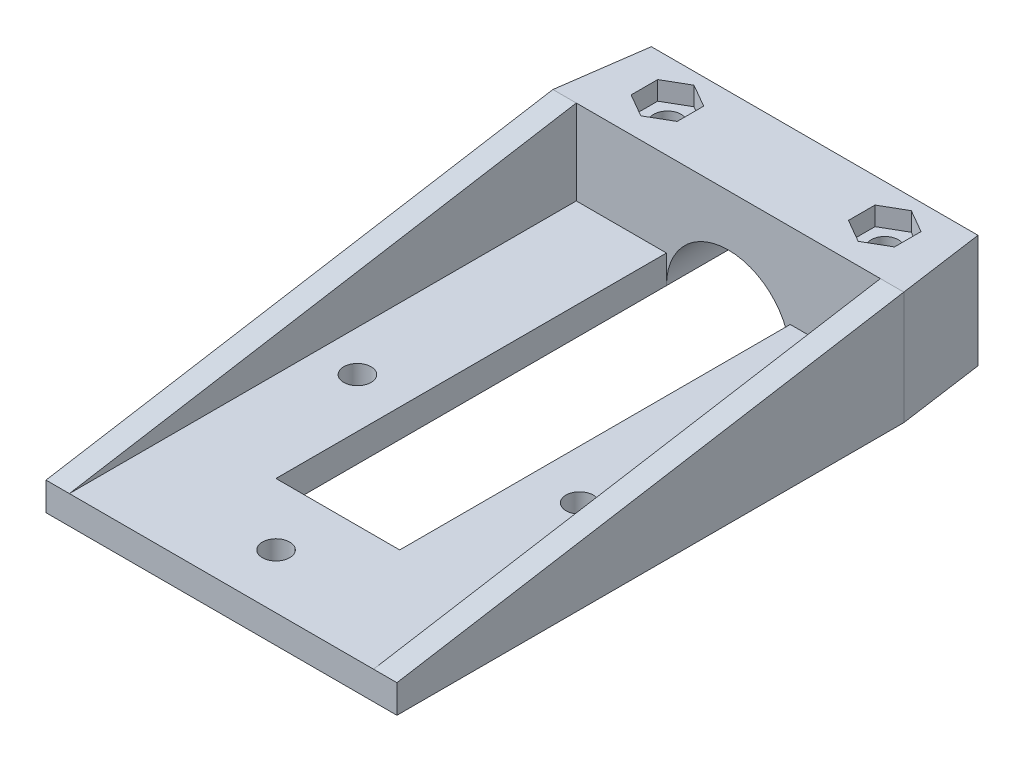
from build123d import *

# Parameters (mm, degrees)
BOSS_EXTRUDE3_DEPTH              = 14.5
SKETCH8_R                        = 7.935
CUT_EXTRUDE3_DEPTH               = 88
CUT_EXTRUDE9_DEPTH               = 2.4
F_39_0_13779528_DIAMETER_HOLE1_D = 3.500000112
CUT_EXTRUDE10_DEPTH              = 22.4
CUT_EXTRUDE11_DEPTH              = 2.4
BOSS_EXTRUDE7_DEPTH              = 3.625
F_39_0_13779528_DIAMETER_HOLE2_D = 3.500000112
BOSS_EXTRUDE10_DEPTH             = 3
BOSS_EXTRUDE11_DEPTH             = 3


with BuildPart() as part:
    # Sketch6 → Boss-Extrude3 (new body)
    with BuildSketch(Plane(origin=(0, 0, 0), x_dir=(1, 0, 0), z_dir=(0, 1, 0))):
        Polygon((-16.836914056, 5.783353512), (13.163085944, 5.783353512), (20.663085944, -47.581919406), (-24.336914056, -47.581919406), align=None)
    extrude(amount=BOSS_EXTRUDE3_DEPTH)

    # Sketch8 → Cut-Extrude3 (cut)
    with BuildSketch(Plane.XY.offset(47.581919406)):
        with Locations((-1.836914056, 0)):
            Circle(SKETCH8_R)
    extrude(amount=-CUT_EXTRUDE3_DEPTH, mode=Mode.SUBTRACT)

    # Sketch18 → Cut-Extrude9 (cut)
    with BuildSketch(Plane(origin=(0, 14.5, 0), x_dir=(1, 0, 0), z_dir=(0, 1, 0))):
        Polygon((-15.771819769, -44.868285994), (-12.821819769, -43.1651027), (-12.821819769, -39.758736112), (-15.771819769, -38.055552818), (-18.721819769, -39.758736112), (-18.721819769, -43.1651027), align=None)
        Polygon((12.097991657, -44.868285994), (15.047991657, -43.1651027), (15.047991657, -39.758736112), (12.097991657, -38.055552818), (9.147991657, -39.758736112), (9.147991657, -43.1651027), align=None)
        Polygon((11.389331688, -26.016021021), (14.389331688, -24.283970214), (14.389331688, -20.819868599), (11.389331688, -19.087817791), (8.389331688, -20.819868599), (8.389331688, -24.283970214), align=None)
        Polygon((-15.0631598, -26.016021021), (-12.0631598, -24.283970214), (-12.0631598, -20.819868599), (-15.0631598, -19.087817791), (-18.0631598, -20.819868599), (-18.0631598, -24.283970214), align=None)
    extrude(amount=-CUT_EXTRUDE9_DEPTH, mode=Mode.SUBTRACT)

    # #39 (0.13779528) Diameter Hole1 (through all)
    with Locations(Plane(origin=(-15.0631598, 14.5, 22.551919406), x_dir=(0, 0, 1), z_dir=(0, 1, 0))):
        with Locations((0, 0), (0, 26.452491488), (18.91, -0.708659969), (18.91, 27.161151457)):
            Hole(F_39_0_13779528_DIAMETER_HOLE1_D / 2)

    # Sketch22 → Cut-Extrude10 (cut)
    with BuildSketch(Plane(origin=(0, 14.5, 0), x_dir=(1, 0, 0), z_dir=(0, 1, 0))):
        Polygon((-22.781301734, -36.51316259), (19.107473622, -36.51316259), (13.163085944, 5.783353512), (-16.836914056, 5.783353512), align=None)
    extrude(amount=-CUT_EXTRUDE10_DEPTH, mode=Mode.SUBTRACT)

    # Sketch24 → Cut-Extrude11 (cut)
    with BuildSketch(Plane.XZ):
        Polygon((-15.771819769, 38.055552818), (-12.821819769, 39.758736112), (-12.821819769, 43.1651027), (-15.771819769, 44.868285994), (-18.721819769, 43.1651027), (-18.721819769, 39.758736112), align=None)
        Polygon((12.097991657, 38.055552818), (15.047991657, 39.758736112), (15.047991657, 43.1651027), (12.097991657, 44.868285994), (9.147991657, 43.1651027), (9.147991657, 39.758736112), align=None)
    extrude(amount=-CUT_EXTRUDE11_DEPTH, mode=Mode.SUBTRACT)

    # Sketch27 → Boss-Extrude7 (add)
    with BuildSketch(Plane(origin=(0, 0, 0), x_dir=(1, 0, 0), z_dir=(0, 1, 0))):
        Polygon((6.098085944, -47.581919406), (20.663085944, -47.581919406), (20.663085944, -112.581919406), (-9.771914056, -112.581919406), (-24.336914056, -112.581919406), (-24.336914056, -47.581919406), (-9.771914056, -47.581919406), (-9.771914056, -97.661919406), (6.098085944, -97.661919406), align=None)
    extrude(amount=BOSS_EXTRUDE7_DEPTH)

    # #39 (0.13779528) Diameter Hole2 (through all)
    with Locations(Plane(origin=(-16.086914056, 3.625, 80.900195398), x_dir=(0, 0, 1), z_dir=(0, 1, 0))):
        with Locations((0, 0), (24.681724008, 14.25), (0, 28.5)):
            Hole(F_39_0_13779528_DIAMETER_HOLE2_D / 2)

    # Sketch39 → Boss-Extrude10 (add)
    with BuildSketch(Plane(origin=(20.663085944, 0, 0), x_dir=(0, 0, -1), z_dir=(1, 0, 0))):
        Polygon((-47.581919406, 14.5), (-112.581919406, 3.625), (-47.581919406, 3.625), align=None)
    extrude(amount=-BOSS_EXTRUDE10_DEPTH)

    # Sketch40 → Boss-Extrude11 (add)
    with BuildSketch(Plane.ZY.offset(24.336914056)):
        Polygon((47.581919406, 14.5), (112.581919406, 3.625), (47.581919406, 3.625), align=None)
    extrude(amount=-BOSS_EXTRUDE11_DEPTH)


solid = part.part
